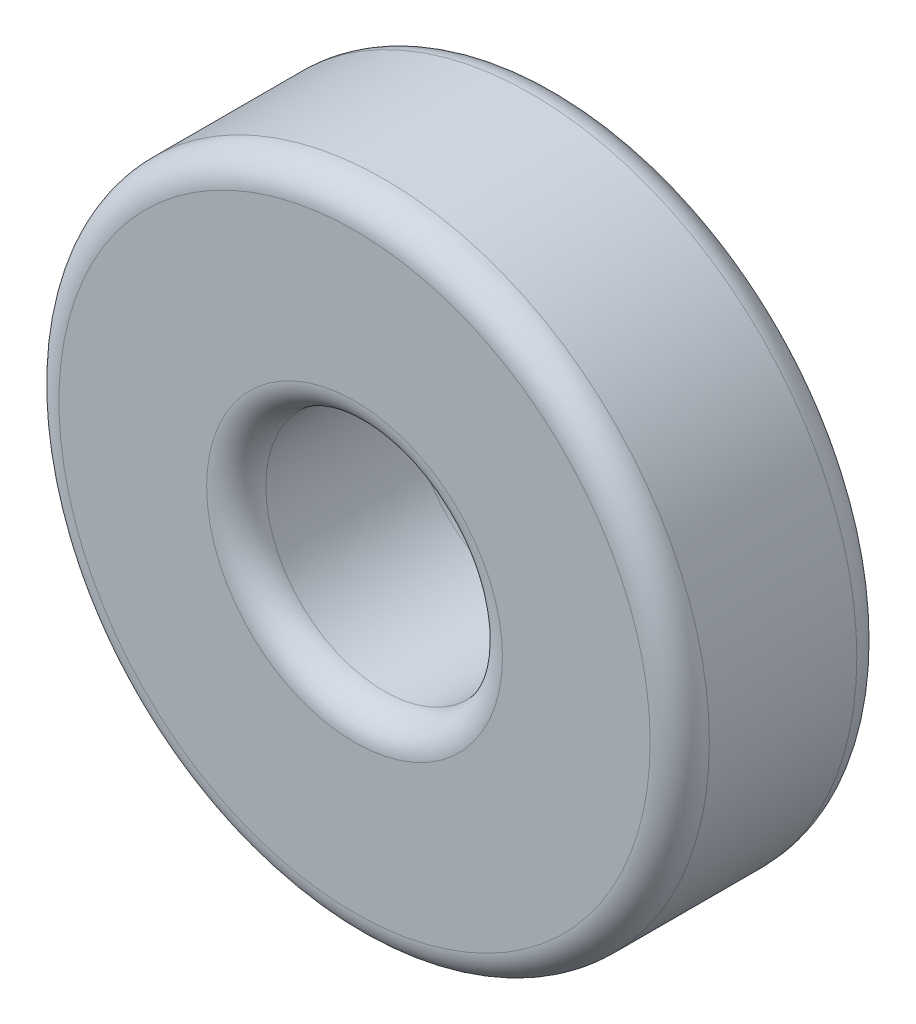
from build123d import *

# Parameters (mm, degrees)
SKETCH1_R           = 10.99185
SKETCH1_R_2         = 4
BOSS_EXTRUDE1_DEPTH = 6.985
FILLET2_R           = 1


with BuildPart() as part:
    # Sketch1 → Boss-Extrude1 (new body)
    with BuildSketch(Plane.XY):
        Circle(SKETCH1_R)
        Circle(SKETCH1_R_2, mode=Mode.SUBTRACT)
    extrude(amount=BOSS_EXTRUDE1_DEPTH)

    # Fillet2
    fillet2_edges = [part.edges().sort_by_distance(p)[0] for p in [
        (-10.99185, 0, 0),
        (-10.99185, 0, 6.985),
        (-4, 0, 0),
        (-4, 0, 6.985),
    ]]
    fillet(fillet2_edges, radius=FILLET2_R)


solid = part.part
